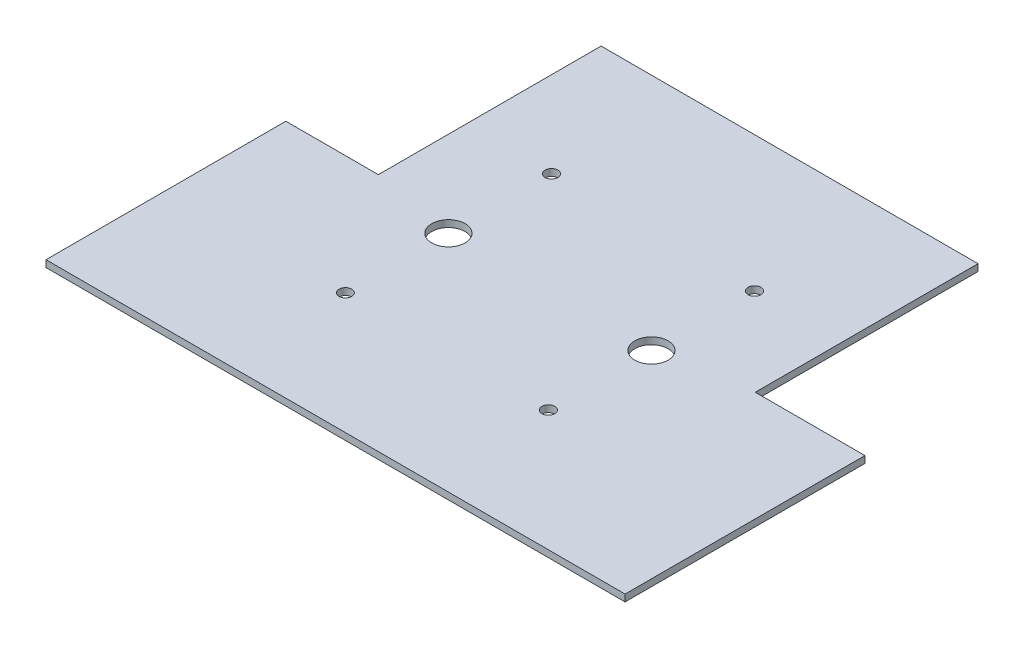
from build123d import *

# Parameters (mm, degrees)
AUFSATZ_LINEAR_AUSTRAGEN1_DEPTH = 2
SKIZZE2_R                       = 4.875
SCHNITT_LINEAR_AUSTRAGEN1_DEPTH = 2
SKIZZE3_R                       = 4.875
SCHNITT_LINEAR_AUSTRAGEN2_DEPTH = 2
SKIZZE4_R                       = 1.875
SCHNITT_LINEAR_AUSTRAGEN3_DEPTH = 2
SKIZZE5_R                       = 1.845307759
SCHNITT_LINEAR_AUSTRAGEN4_DEPTH = 2
SKIZZE6_R                       = 1.875
SCHNITT_LINEAR_AUSTRAGEN5_DEPTH = 2
SKIZZE7_R                       = 1.875
SCHNITT_LINEAR_AUSTRAGEN6_DEPTH = 2


with BuildPart() as part:
    # Skizze1 → Aufsatz-Linear austragen1 (new body)
    with BuildSketch(Plane(origin=(0, 0, 0), x_dir=(1, 0, 0), z_dir=(0, 1, 0))):
        Polygon((142, -65), (110, -65), (110, 0), (0, 0), (0, -65), (-27, -65), (-27, -135), (142, -135), align=None)
    extrude(amount=AUFSATZ_LINEAR_AUSTRAGEN1_DEPTH)

    # Skizze2 → Schnitt-Linear austragen1 (cut)
    with BuildSketch(Plane(origin=(0, 2, 0), x_dir=(1, 0, 0), z_dir=(0, 1, 0))):
        with Locations((25.044083651, -69.597933498)):
            Circle(SKIZZE2_R)
    extrude(amount=-SCHNITT_LINEAR_AUSTRAGEN1_DEPTH, mode=Mode.SUBTRACT)

    # Skizze3 → Schnitt-Linear austragen2 (cut)
    with BuildSketch(Plane(origin=(0, 2, 0), x_dir=(1, 0, 0), z_dir=(0, 1, 0))):
        with Locations((84.294083651, -69.597933498)):
            Circle(SKIZZE3_R)
    extrude(amount=-SCHNITT_LINEAR_AUSTRAGEN2_DEPTH, mode=Mode.SUBTRACT)

    # Skizze4 → Schnitt-Linear austragen3 (cut)
    with BuildSketch(Plane(origin=(0, 2, 0), x_dir=(1, 0, 0), z_dir=(0, 1, 0))):
        with Locations((84.294083651, -99.672933498)):
            Circle(SKIZZE4_R)
    extrude(amount=-SCHNITT_LINEAR_AUSTRAGEN3_DEPTH, mode=Mode.SUBTRACT)

    # Skizze5 → Schnitt-Linear austragen4 (cut)
    with BuildSketch(Plane(origin=(0, 2, 0), x_dir=(1, 0, 0), z_dir=(0, 1, 0))):
        with Locations((25.044083651, -99.672933498)):
            Circle(SKIZZE5_R)
    extrude(amount=-SCHNITT_LINEAR_AUSTRAGEN4_DEPTH, mode=Mode.SUBTRACT)

    # Skizze6 → Schnitt-Linear austragen5 (cut)
    with BuildSketch(Plane(origin=(0, 2, 0), x_dir=(1, 0, 0), z_dir=(0, 1, 0))):
        with Locations((84.294083651, -39.522933498)):
            Circle(SKIZZE6_R)
    extrude(amount=-SCHNITT_LINEAR_AUSTRAGEN5_DEPTH, mode=Mode.SUBTRACT)

    # Skizze7 → Schnitt-Linear austragen6 (cut)
    with BuildSketch(Plane(origin=(0, 2, 0), x_dir=(1, 0, 0), z_dir=(0, 1, 0))):
        with Locations((25.044083651, -39.522933498)):
            Circle(SKIZZE7_R)
    extrude(amount=-SCHNITT_LINEAR_AUSTRAGEN6_DEPTH, mode=Mode.SUBTRACT)


solid = part.part
